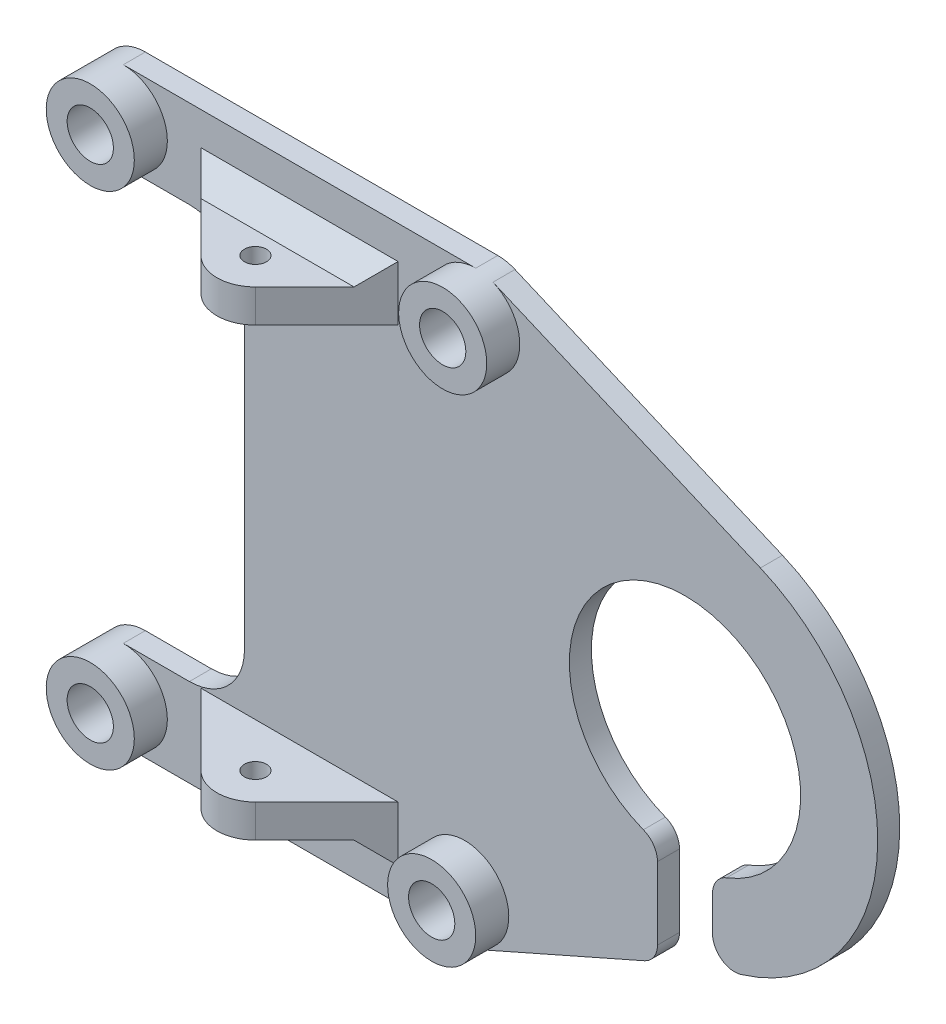
from build123d import *

# Parameters (mm, degrees)
SKETCH1_R                = 2.1
BOSS_EXTRUDE1_DEPTH      = 2
BOSS_EXTRUDE2_START      = -8
SKETCH2_R                = 1
BOSS_EXTRUDE2_DEPTH      = 3
CHAMFER1_SIZE            = 2
CHAMFER1_OF_MIRROR2_SIZE = 2
SKETCH3_R                = 4
SKETCH3_R_2              = 2.1
BOSS_EXTRUDE3_DEPTH      = 3


with BuildPart() as part:
    # Sketch1 → Boss-Extrude1 (new body)
    with BuildSketch(Plane.XY):
        with BuildLine():
            Line((-16, -26.75), (16, -26.75))
            ThreePointArc((16, -26.75), (16.337730018, -26.650061333), (16.665698596, -26.521663849))
            Line((16.665698596, -26.521663849), (31.3079825, -20.055119449))
            ThreePointArc((31.3079825, -20.055119449), (32.175703584, -19.31738929), (32.5, -18.225593751))
            Line((32.5, -18.225593751), (32.5, -11.66190379))
            ThreePointArc((32.5, -11.66190379), (32.14924225, -10.53053294), (31.22, -9.795999183))
            ThreePointArc((31.22, -9.795999183), (35, 10.5), (38.78, -9.795999183))
            ThreePointArc((38.78, -9.795999183), (37.85075775, -10.53053294), (37.5, -11.66190379))
            Line((37.5, -11.66190379), (37.5, -14.832396974))
            ThreePointArc((37.5, -14.832396974), (38.308633206, -16.438835632), (40.080645161, -16.746254648))
            ThreePointArc((40.080645161, -16.746254648), (52.47471331, -0.940422641), (41.848535598, 16.104271488))
            Line((41.848535598, 16.104271488), (17.565379565, 26.43097634))
            ThreePointArc((17.565379565, 26.43097634), (16.798778642, 26.669432699), (16, 26.75))
            Line((16, 26.75), (-16, 26.75))
            ThreePointArc((-16, 26.75), (-20, 22.75), (-16, 18.75))
            Line((-16, 18.75), (-10, 18.75))
            ThreePointArc((-10, 18.75), (-6.464466094, 17.285533906), (-5, 13.75))
            Line((-5, 13.75), (-5, -13.75))
            ThreePointArc((-5, -13.75), (-6.464466094, -17.285533906), (-10, -18.75))
            Line((-10, -18.75), (-16, -18.75))
            ThreePointArc((-16, -18.75), (-20, -22.75), (-16, -26.75))
        make_face()
        with Locations((-16, 22.75)):
            Circle(SKETCH1_R, mode=Mode.SUBTRACT)
        with Locations((16, 22.75)):
            Circle(SKETCH1_R, mode=Mode.SUBTRACT)
        with Locations((15, -22.75)):
            Circle(SKETCH1_R, mode=Mode.SUBTRACT)
        with Locations((-16, -22.75)):
            Circle(SKETCH1_R, mode=Mode.SUBTRACT)
    extrude(amount=BOSS_EXTRUDE1_DEPTH)

    # Sketch2 → Boss-Extrude2 (add)
    with BuildSketch(Plane.XZ.offset(26.75).offset(BOSS_EXTRUDE2_START)):
        with BuildLine():
            Line((-2.474873734, 8.474873734), (-8.949747468, 2))
            Line((-8.949747468, 2), (8.949747468, 2))
            Line((8.949747468, 2), (2.474873734, 8.474873734))
            ThreePointArc((2.474873734, 8.474873734), (0, 9.5), (-2.474873734, 8.474873734))
        make_face()
        with Locations((0, 6)):
            Circle(SKETCH2_R, mode=Mode.SUBTRACT)
    boss_extrude2 = extrude(amount=BOSS_EXTRUDE2_DEPTH)

    # Chamfer1
    chamfer1_edges = [part.edges().sort_by_distance(p)[0] for p in [
        (0, -21.75, 2),
    ]]
    chamfer(chamfer1_edges, length=CHAMFER1_SIZE)

    # Mirror2: Boss-Extrude2 across plane
    add(boss_extrude2.mirror(Plane.ZX))

    # Chamfer1 of Mirror2
    chamfer1_of_mirror2_edges = [part.edges().sort_by_distance(p)[0] for p in [
        (0, 21.75, 2),
    ]]
    chamfer(chamfer1_of_mirror2_edges, length=CHAMFER1_OF_MIRROR2_SIZE)

    # Sketch3 → Boss-Extrude3 (add)
    with BuildSketch(Plane.XY.offset(2)):
        with Locations((-16, -22.75)):
            Circle(SKETCH3_R)
        with Locations((-16, -22.75)):
            Circle(SKETCH3_R_2, mode=Mode.SUBTRACT)
        with Locations((15, -22.75)):
            Circle(SKETCH3_R)
        with Locations((15, -22.75)):
            Circle(SKETCH3_R_2, mode=Mode.SUBTRACT)
        with Locations((16, 22.75)):
            Circle(SKETCH3_R)
        with Locations((16, 22.75)):
            Circle(SKETCH3_R_2, mode=Mode.SUBTRACT)
        with Locations((-16, 22.75)):
            Circle(SKETCH3_R)
        with Locations((-16, 22.75)):
            Circle(SKETCH3_R_2, mode=Mode.SUBTRACT)
    extrude(amount=BOSS_EXTRUDE3_DEPTH)


solid = part.part
